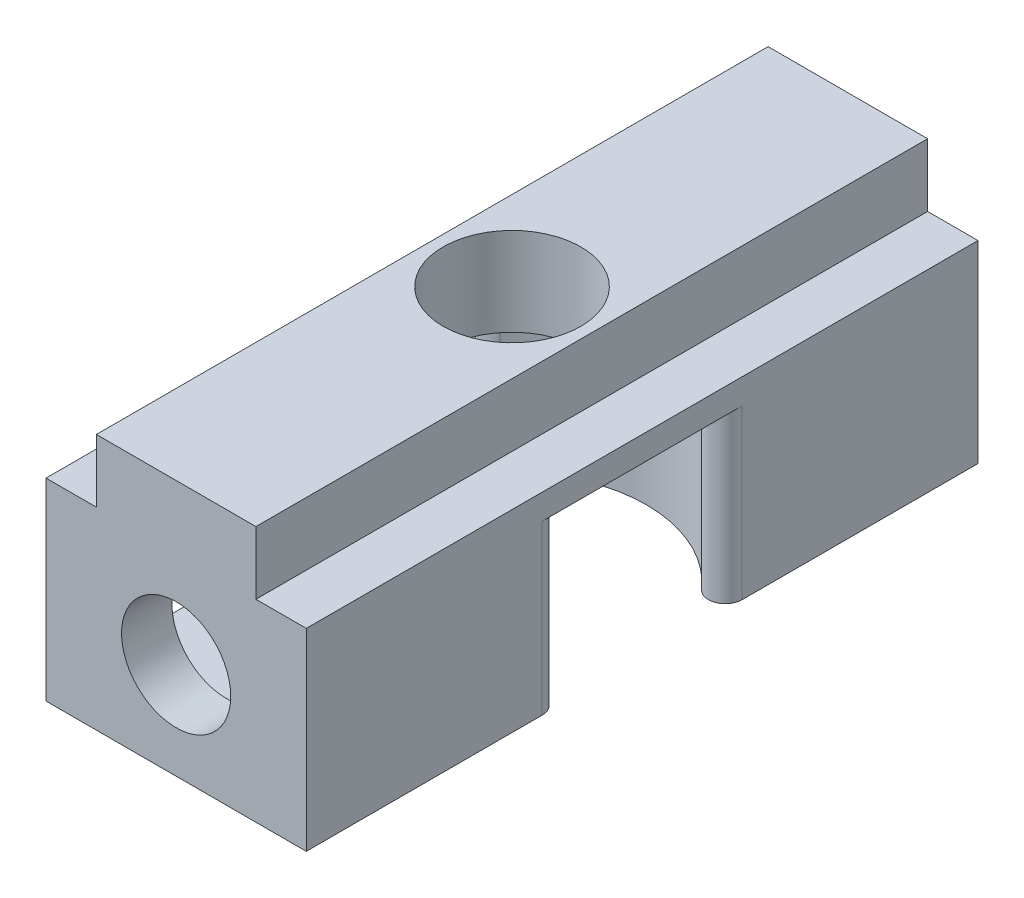
from build123d import *

# Parameters (mm, degrees)
BOSS_EXTRUDE1_DEPTH = 40
CUT_EXTRUDE1_REACH  = 17.25
SKETCH2_R           = 4.1
SKETCH3_R           = 8
CUT_EXTRUDE2_DEPTH  = 10
FILLET1_R           = 1
CUT_EXTRUDE3_DEPTH  = 6
CUT_EXTRUDE4_REACH  = 17.5
SKETCH6_W           = 10
SKETCH6_H           = 6
SKETCH4_R           = 3.25
CUT_EXTRUDE5_DEPTH  = 3


with BuildPart() as part:
    # Sketch1 → Boss-Extrude1 (new body)
    with BuildSketch(Plane(origin=(0, 0, 0), x_dir=(0, 1, 0), z_dir=(0, 0, 1))):
        Polygon((0, 0), (0, 15.5), (11.5, 15.5), (11.5, 12.5), (15.25, 12.5), (15.25, 3), (11.5, 3), (11.5, 0), align=None)
    extrude(amount=BOSS_EXTRUDE1_DEPTH)

    # Sketch2 → Cut-Extrude1 (cut, up to next)
    with BuildSketch(Plane(origin=(0, 15.25, 0), x_dir=(-1, 0, 0), z_dir=(0, 1, 0)), mode=Mode.PRIVATE) as cut_extrude1_sk1:
        with Locations((7.75, 20)):
            Circle(SKETCH2_R)
    cut_extrude1_tool1 = extrude(cut_extrude1_sk1.sketch, amount=-CUT_EXTRUDE1_REACH, mode=Mode.PRIVATE) & part.part
    add(cut_extrude1_tool1.solids().sort_by_distance((-7.75, 15.25, 20))[0], mode=Mode.SUBTRACT)

    # Sketch3 → Cut-Extrude2 (cut)
    with BuildSketch(Plane.XZ):
        with Locations((-7.75, 20)):
            Circle(SKETCH3_R)
    extrude(amount=-CUT_EXTRUDE2_DEPTH, mode=Mode.SUBTRACT)

    # Fillet1
    fillet1_edges = [part.edges().sort_by_distance(p)[0] for p in [
        (0, 5, 18.015686517),
        (-15.5, 5, 18.015686517),
        (0, 5, 21.984313483),
        (-15.5, 5, 21.984313483),
    ]]
    fillet(fillet1_edges, radius=FILLET1_R)

    # Sketch5 → Cut-Extrude3 (cut)
    with BuildSketch(Plane.XY.offset(37)):
        Polygon((-1.976497308, 5.75), (-4.863248654, 10.75), (-10.636751346, 10.75), (-13.523502692, 5.75), (-10.636751346, 0.75), (-4.863248654, 0.75), align=None)
    extrude(amount=-CUT_EXTRUDE3_DEPTH, mode=Mode.SUBTRACT)

    # Sketch6 → Cut-Extrude4 (cut, up to next)
    with BuildSketch(Plane(origin=(-15.5, 0, 0), x_dir=(0, -1, 0), z_dir=(-1, 0, 0)), mode=Mode.PRIVATE) as cut_extrude4_sk1:
        with Locations((-5.75, 34)):
            Rectangle(SKETCH6_W, SKETCH6_H)
    cut_extrude4_tool1 = extrude(cut_extrude4_sk1.sketch, amount=-CUT_EXTRUDE4_REACH, mode=Mode.PRIVATE) & part.part
    add(cut_extrude4_tool1.solids().sort_by_distance((-15.5, 5.75, 34))[0], mode=Mode.SUBTRACT)

    # Sketch4 → Cut-Extrude5 (cut)
    with BuildSketch(Plane.XY.offset(40)):
        with Locations((-7.75, 5.75)):
            Circle(SKETCH4_R)
    extrude(amount=-CUT_EXTRUDE5_DEPTH, mode=Mode.SUBTRACT)


solid = part.part
